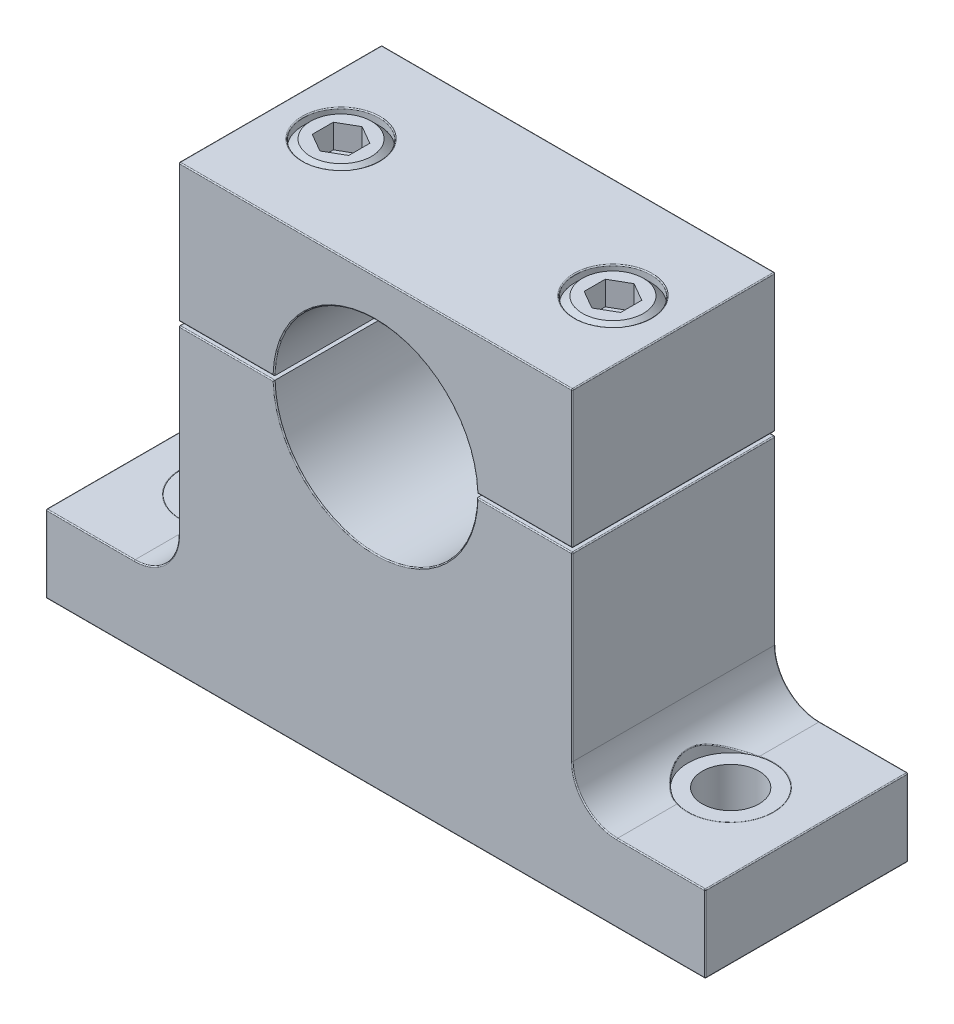
from build123d import *

# Parameters (mm, degrees)
BOSS_EXTRUDE1_DEPTH     = 12.7
BOSS_EXTRUDE1_2_DEPTH   = 12.7
SKETCH4_R               = 3.556
CUT_EXTRUDE1_DEPTH      = 64.029276017
SKETCH5_R               = 5.334
CUT_EXTRUDE2_DEPTH      = 64.029276017
CUT_EXTRUDE2_DEPTH_BACK = 0.02
SKETCH6_R               = 4.7625
CUT_EXTRUDE3_DEPTH      = 6.35
SKETCH8_R               = 3.175
CUT_EXTRUDE4_DEPTH      = 66.473550261
CUT_EXTRUDE5_DEPTH      = 3
CHAMFER1_SIZE           = 0.9525
FILLET1_R               = 0.127
FILLET2_R               = 0.127


with BuildPart() as part:
    # Sketch2 → Boss-Extrude1 (new, symmetric)
    with BuildSketch(Plane.XY):
        with BuildLine():
            Line((-24.638, 17.4625), (24.638, 17.4625))
            Line((24.638, 17.4625), (24.638, 0.25))
            Line((24.638, 0.25), (12.697539132, 0.25))
            ThreePointArc((12.697539132, 0.25), (0, 12.7), (-12.697539132, 0.25))
            Line((-12.697539132, 0.25), (-24.638, 0.25))
            Line((-24.638, 0.25), (-24.638, 17.4625))
        make_face()
    extrude(amount=BOSS_EXTRUDE1_DEPTH, both=True)

    # Sketch6 → Cut-Extrude3 (cut)
    with BuildSketch(Plane(origin=(0, 17.4625, 0), x_dir=(1, 0, 0), z_dir=(0, 1, 0))):
        with Locations(Location((17.018, 0, 0), (0, 0, 180))):
            Circle(SKETCH6_R)
        with Locations(Location((-17.018, 0, 0), (0, 0, 180))):
            Circle(SKETCH6_R)
    extrude(amount=-CUT_EXTRUDE3_DEPTH, mode=Mode.SUBTRACT)


with BuildPart() as body_2:
    # Sketch2 → Boss-Extrude1 2 (new, symmetric)
    with BuildSketch(Plane.XY):
        with BuildLine():
            Line((41.275, -38.1), (-41.275, -38.1))
            Line((-41.275, -38.1), (-41.275, -28.448))
            Line((-41.275, -28.448), (-30.19425, -28.448))
            ThreePointArc((-30.19425, -28.448), (-26.265387947, -26.820612053), (-24.638, -22.89175))
            Line((-24.638, -22.89175), (-24.638, -0.25))
            Line((-24.638, -0.25), (-12.697539132, -0.25))
            ThreePointArc((-12.697539132, -0.25), (0, -12.7), (12.697539132, -0.25))
            Line((12.697539132, -0.25), (24.638, -0.25))
            Line((24.638, -0.25), (24.638, -22.89175))
            ThreePointArc((24.638, -22.89175), (26.265387947, -26.820612053), (30.19425, -28.448))
            Line((30.19425, -28.448), (41.275, -28.448))
            Line((41.275, -28.448), (41.275, -38.1))
        make_face()
    extrude(amount=BOSS_EXTRUDE1_2_DEPTH, both=True)

    # Sketch4 → Cut-Extrude1 (cut, through all)
    with BuildSketch(Plane(origin=(0, -28.448, 0), x_dir=(1, 0, 0), z_dir=(0, 1, 0))):
        with Locations(Location((-31.75, 0, 0), (0, 0, 180))):
            Circle(SKETCH4_R)
        with Locations(Location((31.75, 0, 0), (0, 0, 180))):
            Circle(SKETCH4_R)
    extrude(amount=-CUT_EXTRUDE1_DEPTH, mode=Mode.SUBTRACT)

    # Sketch5 → Cut-Extrude2 (cut, two sides)
    with BuildSketch(Plane(origin=(0, -28.448, 0), x_dir=(1, 0, 0), z_dir=(0, 1, 0))) as cut_extrude2_sk:
        with Locations(Location((31.75, 0, 0), (0, 0, 253.0422367))):
            Circle(SKETCH5_R)
        with Locations(Location((-31.75, 0, 0), (0, 0, 286.9577633))):
            Circle(SKETCH5_R)
    extrude(amount=CUT_EXTRUDE2_DEPTH, mode=Mode.SUBTRACT)
    extrude(cut_extrude2_sk.sketch, amount=-CUT_EXTRUDE2_DEPTH_BACK, mode=Mode.SUBTRACT)


with BuildPart() as cut_extrude4_tool:
    # Sketch8 → Cut-Extrude4 (new, through all)
    with BuildSketch(Plane(origin=(0, 11.1125, 0), x_dir=(1, 0, 0), z_dir=(0, 1, 0))):
        with Locations(Location((17.018, 0, 0), (0, 0, 180))):
            Circle(SKETCH8_R)
        with Locations(Location((-17.018, 0, 0), (0, 0, 180))):
            Circle(SKETCH8_R)
    extrude(amount=-CUT_EXTRUDE4_DEPTH)


with BuildPart() as part_1:
    add(part.part)

    # Cut-Extrude4: cut by cut_extrude4_tool
    add(cut_extrude4_tool.part, mode=Mode.SUBTRACT)

    # Fillet2
    fillet2_edges = [part_1.edges().sort_by_distance(p)[0] for p in [
        (0, 12.7, 12.7),
        (-24.638, 17.4625, 0),
        (24.638, 17.4625, 0),
        (24.638, 0.25, 0),
        (-24.638, 0.25, 0),
        (18.667769566, 0.25, 12.7),
        (24.638, 8.85625, 12.7),
        (0, 17.4625, 12.7),
        (21.7805, 17.4625, 0),
        (-12.2555, 17.4625, 0),
        (-24.638, 8.85625, 12.7),
        (0, 17.4625, -12.7),
        (24.638, 8.85625, -12.7),
        (18.667769566, 0.25, -12.7),
        (-18.667769566, 0.25, 12.7),
        (0, 12.7, -12.7),
        (-18.667769566, 0.25, -12.7),
        (-24.638, 8.85625, -12.7),
    ]]
    fillet(fillet2_edges, radius=FILLET2_R)


with BuildPart() as body_2_1:
    add(body_2.part)

    # Cut-Extrude4: cut by cut_extrude4_tool
    add(cut_extrude4_tool.part, mode=Mode.SUBTRACT)

    # Fillet1
    fillet1_edges = [body_2_1.edges().sort_by_distance(p)[0] for p in [
        (26.416, -26.965659793, 0),
        (-26.416, -26.965659793, 0),
        (35.306, -38.1, 0),
        (-28.194, -38.1, 0),
        (-13.843, -38.1, 0),
        (20.193, -38.1, 0),
        (41.275, -38.1, 0),
        (41.275, -28.448, 0),
        (24.638, -0.25, 0),
        (-24.638, -0.25, 0),
        (-41.275, -28.448, 0),
        (-41.275, -38.1, 0),
        (35.734625, -28.448, -12.7),
        (26.265387947, -26.820612053, -12.7),
        (24.638, -11.570875, -12.7),
        (18.667769566, -0.25, -12.7),
        (0, -12.7, -12.7),
        (-18.667769566, -0.25, -12.7),
        (-24.638, -11.570875, -12.7),
        (-26.265387947, -26.820612053, -12.7),
        (-35.734625, -28.448, -12.7),
        (-41.275, -33.274, -12.7),
        (0, -38.1, -12.7),
        (41.275, -33.274, -12.7),
        (0, -38.1, 12.7),
        (-41.275, -33.274, 12.7),
        (-35.734625, -28.448, 12.7),
        (-26.265387947, -26.820612053, 12.7),
        (-24.638, -11.570875, 12.7),
        (-18.667769566, -0.25, 12.7),
        (0, -12.7, 12.7),
        (18.667769566, -0.25, 12.7),
        (24.638, -11.570875, 12.7),
        (26.265387947, -26.820612053, 12.7),
        (35.734625, -28.448, 12.7),
        (41.275, -33.274, 12.7),
    ]]
    fillet(fillet1_edges, radius=FILLET1_R)


with BuildPart() as body_3:
    # Sketch10 → Revolve1 (revolve)
    with BuildSketch(Plane.XY):
        Polygon((-17.018, 17.4625), (-12.2555, 17.4625), (-12.2555, 11.1125), (-13.843, 11.1125), (-13.843, -38.1), (-17.018, -38.1), align=None)
    revolve(axis=Axis((-17.018, -38.1, 0), (0, 1, 0)))

    # Sketch11 → Cut-Extrude5 (cut)
    with BuildSketch(Plane(origin=(0, 17.4625, 0), x_dir=(1, 0, 0), z_dir=(0, 1, 0))):
        Polygon((-17.018, 2.639645431), (-19.304, 1.319822715), (-19.304, -1.319822715), (-17.018, -2.639645431), (-14.732, -1.319822715), (-14.732, 1.319822715), align=None)
    extrude(amount=-CUT_EXTRUDE5_DEPTH, mode=Mode.SUBTRACT)

    # Chamfer1
    chamfer1_edges = [body_3.edges().sort_by_distance(p)[0] for p in [
        (-21.7805, 17.4625, 0),
    ]]
    chamfer(chamfer1_edges, length=CHAMFER1_SIZE)


with BuildPart() as body_4:
    # Mirror1: mirrored copy
    add(body_3.part.mirror(Plane(origin=(0, 0, 0), x_dir=(0, 0, 1), z_dir=(1, 0, 0))))


solid = Compound([part_1.part, body_2_1.part, body_3.part, body_4.part])
